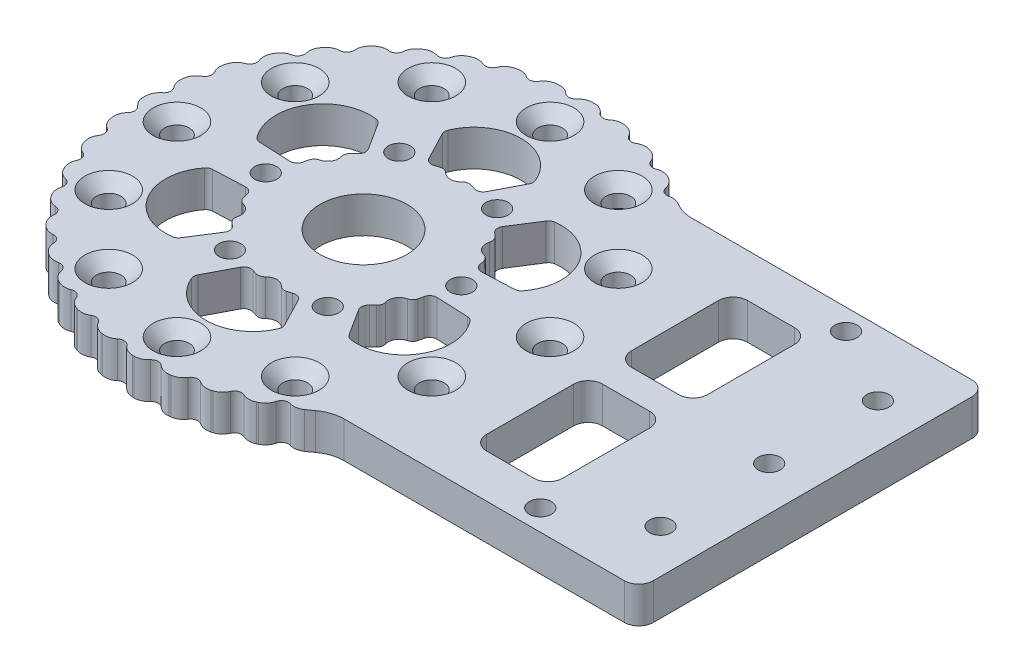
from build123d import *

# Parameters (mm, degrees)
EXTRUDE_1_DEPTH                = 5
SKETCH_2_R                     = 1.275
CUT_EXTRUDE_1_DEPTH            = 6
SKETCH_5_R                     = 10
CUT_EXTRUDE_3_DEPTH            = 6
SKETCH_6_R                     = 1.525
CUT_EXTRUDE_4_DEPTH            = 6
SKETCH_9_R                     = 12.5
CUT_EXTRUDE_7_DEPTH            = 6
HOLE_WIZARD_M3_1_D             = 3.6
HOLE_WIZARD_M3_1_CSINK_D       = 6.6
HOLE_WIZARD_M3_1_CSINK_ANGLE   = 90
HOLE_WIZARD_1_D                = 3
HOLE_WIZARD_1_CSINK_D          = 6
HOLE_WIZARD_1_CSINK_ANGLE      = 90
SKETCH_3_R                     = 2.025
CUT_EXTRUDE_8_DEPTH            = 10
SKETCH_14_R                    = 37
EXTRUDE_2_DEPTH                = 5
SKETCH_15_R                    = 42.5
EXTRUDE_3_DEPTH                = 5
SKETCH_16_R                    = 1.525
CUT_EXTRUDE_9_DEPTH            = 5
CUT_EXTRUDE_10_DEPTH           = 5
PATTERN_CIRCULAR_1_COUNT       = 6
SKETCH_19_R                    = 6
CUT_EXTRUDE_11_DEPTH           = 5
FILLET_1_R                     = 2
CUT_EXTRUDE_13_DEPTH           = 6
FILLET_2_R                     = 1
SKETCH_22_W                    = 180
SKETCH_22_H                    = 48
CUT_EXTRUDE_14_DEPTH           = 6.0000001
SKETCH_23_R                    = 1.525
CUT_EXTRUDE_15_DEPTH           = 6.0000001
SKETCH_27_R                    = 1.525
CUT_EXTRUDE_16_DEPTH           = 6.0000001
SKETCH_28_W                    = 10.5
SKETCH_28_H                    = 16
CUT_EXTRUDE_17_DEPTH           = 6.0000001
FILLET_3_R                     = 2
FILLET_5_R                     = 2
FILLET_6_R                     = 5
SKETCH_30_R                    = 1
CUT_EXTRUDE_18_DEPTH           = 6.0000001
PATTERN_CIRCULAR_2_COUNT       = 40
FILLET_7_R                     = 2
SKETCH_31_R                    = 1.525
CUT_EXTRUDE_19_DEPTH           = 6.0000001
SKETCH_32_R                    = 1.525
CUT_EXTRUDE_20_DEPTH           = 6.0000001
SKETCH_33_W                    = 62
SKETCH_33_H                    = 50.134149191
CUT_EXTRUDE_21_DEPTH           = 6.0000001
FILLET_8_R                     = 2
FILLET_9_R                     = 2
HOLE_WIZARD_M3_1_2_D           = 3.4
HOLE_WIZARD_M3_1_2_CSINK_D     = 6.6
HOLE_WIZARD_M3_1_2_CSINK_ANGLE = 90
HOLE_WIZARD_M3_2_D             = 3.4
HOLE_WIZARD_M3_2_CSINK_D       = 6.6
HOLE_WIZARD_M3_2_CSINK_ANGLE   = 90


with BuildPart() as part:
    # 草图1 → 凸台-拉伸1 (new body)
    with BuildSketch(Plane(origin=(0, 0, 0), x_dir=(1, 0, 0), z_dir=(0, 1, 0))):
        with BuildLine():
            Line((105, 24), (-76.839744319, 24))
            ThreePointArc((-76.839744319, 24), (-142, 0), (-76.839744319, -24))
            Line((-76.839744319, -24), (105, -24))
            ThreePointArc((105, -24), (129, 0), (105, 24))
        make_face()
    extrude(amount=EXTRUDE_1_DEPTH)

    # 草图2 → 切除-拉伸1 (cut, through all)
    with BuildSketch(Plane.XZ):
        with Locations((118.435028843, 13.435028843)):
            Circle(SKETCH_2_R)
        with Locations((118.435028843, -13.435028843)):
            Circle(SKETCH_2_R)
        with Locations((91.564971157, -13.435028843)):
            Circle(SKETCH_2_R)
        with Locations((91.564971157, 13.435028843)):
            Circle(SKETCH_2_R)
        with Locations((124, 0)):
            Circle(SKETCH_2_R)
        with Locations((105, -19)):
            Circle(SKETCH_2_R)
        with Locations((86, 0)):
            Circle(SKETCH_2_R)
        with Locations((105, 19)):
            Circle(SKETCH_2_R)
    extrude(amount=-CUT_EXTRUDE_1_DEPTH, mode=Mode.SUBTRACT)

    # 草图5 → 切除-拉伸3 (cut, through all)
    with BuildSketch(Plane(origin=(0, 5, 0), x_dir=(1, 0, 0), z_dir=(0, 1, 0))):
        with Locations((-105, 0)):
            Circle(SKETCH_5_R)
    extrude(amount=-CUT_EXTRUDE_3_DEPTH, mode=Mode.SUBTRACT)

    # 草图6 → 切除-拉伸4 (cut, through all)
    with BuildSketch(Plane(origin=(0, 5, 0), x_dir=(1, 0, 0), z_dir=(0, 1, 0))):
        with Locations((-135, 0)):
            Circle(SKETCH_6_R)
        with Locations((-120, 25.980762114)):
            Circle(SKETCH_6_R)
        with Locations((-90, 25.980762114)):
            Circle(SKETCH_6_R)
        with Locations((-75, 0)):
            Circle(SKETCH_6_R)
        with Locations((-90, -25.980762114)):
            Circle(SKETCH_6_R)
        with Locations((-120, -25.980762114)):
            Circle(SKETCH_6_R)
    extrude(amount=-CUT_EXTRUDE_4_DEPTH, mode=Mode.SUBTRACT)

    # 草图9 → 切除-拉伸7 (cut, through all)
    with BuildSketch(Plane.XZ):
        with Locations((105, 0)):
            Circle(SKETCH_9_R)
    extrude(amount=-CUT_EXTRUDE_7_DEPTH, mode=Mode.SUBTRACT)

    # Hole Wizard M3 _1 (through all)
    with Locations(Plane(origin=(0, 5, 0), x_dir=(1, 0, 0), z_dir=(0, 1, 0))):
        with Locations((105, 19)):
            CounterSinkHole(HOLE_WIZARD_M3_1_D / 2, HOLE_WIZARD_M3_1_CSINK_D / 2, counter_sink_angle=HOLE_WIZARD_M3_1_CSINK_ANGLE)

    # 孔1 (through all)
    with Locations(Plane(origin=(0, 5, 0), x_dir=(1, 0, 0), z_dir=(0, 1, 0))):
        with Locations((91.564971157, 13.435028843), (86, 0), (91.564971157, -13.435028843), (105, -19), (118.435028843, -13.435028843), (124, 0), (118.435028843, 13.435028843)):
            CounterSinkHole(HOLE_WIZARD_1_D / 2, HOLE_WIZARD_1_CSINK_D / 2, counter_sink_angle=HOLE_WIZARD_1_CSINK_ANGLE)

    # 草图3 → 切除-拉伸8 (cut)
    with BuildSketch(Plane(origin=(0, 5, 0), x_dir=(1, 0, 0), z_dir=(0, 1, 0))):
        with Locations((-105, 17.25)):
            Circle(SKETCH_3_R)
        with Locations((-90.061061785, 8.625)):
            Circle(SKETCH_3_R)
        with Locations((-90.061061785, -8.625)):
            Circle(SKETCH_3_R)
        with Locations((-105, -17.25)):
            Circle(SKETCH_3_R)
        with Locations((-119.938938215, -8.625)):
            Circle(SKETCH_3_R)
        with Locations((-119.938938215, 8.625)):
            Circle(SKETCH_3_R)
    extrude(amount=-CUT_EXTRUDE_8_DEPTH, mode=Mode.SUBTRACT)

    # 草图14 → 凸台-拉伸2 (add)
    with BuildSketch(Plane(origin=(0, 5, 0), x_dir=(1, 0, 0), z_dir=(0, 1, 0))):
        with Locations((-105, 0)):
            Circle(SKETCH_14_R)
    extrude(amount=-EXTRUDE_2_DEPTH)

    # 草图15 → 凸台-拉伸3 (add)
    with BuildSketch(Plane(origin=(0, 5, 0), x_dir=(1, 0, 0), z_dir=(0, 1, 0))):
        with Locations((-105, 0)):
            Circle(SKETCH_15_R)
    extrude(amount=-EXTRUDE_3_DEPTH)

    # 草图16 → 切除-拉伸9 (cut)
    with BuildSketch(Plane.XZ):
        with Locations((-105, 13.5)):
            Circle(SKETCH_16_R)
        with Locations((-98.25, 11.691342951)):
            Circle(SKETCH_16_R)
        with Locations((-93.308657049, 6.75)):
            Circle(SKETCH_16_R)
        with Locations((-91.5, 0)):
            Circle(SKETCH_16_R)
        with Locations((-93.308657049, -6.75)):
            Circle(SKETCH_16_R)
        with Locations((-98.25, -11.691342951)):
            Circle(SKETCH_16_R)
        with Locations((-105, -13.5)):
            Circle(SKETCH_16_R)
        with Locations((-111.75, -11.691342951)):
            Circle(SKETCH_16_R)
        with Locations((-116.691342951, -6.75)):
            Circle(SKETCH_16_R)
        with Locations((-118.5, 0)):
            Circle(SKETCH_16_R)
        with Locations((-116.691342951, 6.75)):
            Circle(SKETCH_16_R)
        with Locations((-111.75, 11.691342951)):
            Circle(SKETCH_16_R)
    extrude(amount=-CUT_EXTRUDE_9_DEPTH, mode=Mode.SUBTRACT)

    # 草图18 → 切除-拉伸10 (cut)
    with BuildSketch(Plane(origin=(0, 5, 0), x_dir=(1, 0, 0), z_dir=(0, 1, 0))):
        with BuildLine():
            Line((-98.815341562, 17.25), (-101.45814062, 12.173230244))
            ThreePointArc((-101.45814062, 12.173230244), (-105, 13), (-108.54185938, 12.173230244))
            Line((-108.54185938, 12.173230244), (-111.184658438, 17.25))
            ThreePointArc((-111.184658438, 17.25), (-105, 21.75), (-98.815341562, 17.25))
        make_face()
    cut_extrude_10 = extrude(amount=-CUT_EXTRUDE_10_DEPTH, mode=Mode.SUBTRACT)

    # 阵列(圆周)1: 切除-拉伸10 ×6 about axis
    pattern_circular_1_axis = Axis((-105, 0, 0), (0, 1, 0))
    for i in range(1, PATTERN_CIRCULAR_1_COUNT):
        add(cut_extrude_10.rotate(pattern_circular_1_axis, i * 360 / PATTERN_CIRCULAR_1_COUNT), mode=Mode.SUBTRACT)

    # 草图19 → 切除-拉伸11 (cut)
    with BuildSketch(Plane.XZ):
        with Locations((-105, 0)):
            Circle(SKETCH_19_R)
    extrude(amount=-CUT_EXTRUDE_11_DEPTH, mode=Mode.SUBTRACT)

    # 圆角1
    fillet_1_edges = [part.edges().sort_by_distance(p)[0] for p in [
        (-69.925080185, 2.5, 24),
        (-69.925080185, 2.5, -24),
    ]]
    fillet(fillet_1_edges, radius=FILLET_1_R)

    # 草图21 → 切除-拉伸13 (cut, through all)
    with BuildSketch(Plane.XZ):
        with BuildLine():
            ThreePointArc((-70.508717612, -24.831460674), (-69.797443095, -24.219960864), (-68.885598441, -24))
            Line((-68.885598441, -24), (-85.37858313, -24))
            ThreePointArc((-85.37858313, -24), (-136, 0), (-85.37858313, 24))
            Line((-85.37858313, 24), (-68.885598441, 24))
            ThreePointArc((-68.885598441, 24), (-69.797443095, 24.219960864), (-70.508717612, 24.831460674))
            ThreePointArc((-70.508717612, 24.831460674), (-147.5, 0), (-70.508717612, -24.831460674))
        make_face()
    extrude(amount=-CUT_EXTRUDE_13_DEPTH, mode=Mode.SUBTRACT)

    # 圆角2
    fillet_2_edges = [part.edges().sort_by_distance(p)[0] for p in [
        (-103.607655905, 2.5, -12.877904412),
        (-106.392344095, 2.5, -12.877904412),
        (-101.45814062, 2.5, -12.173230244),
        (-111.184658438, 2.5, -17.25),
        (-98.815341562, 2.5, -17.25),
        (-108.54185938, 2.5, -12.173230244),
        (-93.151235584, 2.5, -5.233146849),
        (-94.543579679, 2.5, -7.644757563),
        (-94.543579679, 2.5, 7.644757563),
        (-93.151235584, 2.5, 5.233146849),
        (-115.456420321, 2.5, -7.644757563),
        (-116.848764416, 2.5, -5.233146849),
        (-116.848764416, 2.5, 5.233146849),
        (-115.456420321, 2.5, 7.644757563),
        (-106.392344095, 2.5, 12.877904412),
        (-103.607655905, 2.5, 12.877904412),
        (-92.686743673, 2.5, -3.019274922),
        (-93.153391004, 2.5, -13.981071321),
        (-86.968732566, 2.5, -3.268928679),
        (-96.228603053, 2.5, -9.153955322),
        (-96.228603053, 2.5, 9.153955322),
        (-86.968732566, 2.5, 3.268928679),
        (-93.153391004, 2.5, 13.981071321),
        (-92.686743673, 2.5, 3.019274922),
        (-108.54185938, 2.5, 12.173230244),
        (-98.815341562, 2.5, 17.25),
        (-111.184658438, 2.5, 17.25),
        (-101.45814062, 2.5, 12.173230244),
        (-117.313256327, 2.5, 3.019274922),
        (-116.846608996, 2.5, 13.981071321),
        (-123.031267434, 2.5, 3.268928679),
        (-113.771396947, 2.5, 9.153955322),
        (-113.771396947, 2.5, -9.153955322),
        (-123.031267434, 2.5, -3.268928679),
        (-116.846608996, 2.5, -13.981071321),
        (-117.313256327, 2.5, -3.019274922),
    ]]
    fillet(fillet_2_edges, radius=FILLET_2_R)

    # 草图22 → 切除-拉伸14 (cut, through all)
    with BuildSketch(Plane.XZ):
        with Locations((55, 0)):
            Rectangle(SKETCH_22_W, SKETCH_22_H)
    extrude(amount=-CUT_EXTRUDE_14_DEPTH, mode=Mode.SUBTRACT)

    # 草图23 → 切除-拉伸15 (cut, through all)
    with BuildSketch(Plane.XZ):
        with Locations((-117.875, 22.300154147)):
            Circle(SKETCH_23_R)
        with Locations((-105, 25.75)):
            Circle(SKETCH_23_R)
        with Locations((-92.125, 22.300154147)):
            Circle(SKETCH_23_R)
        with Locations((-82.699845853, 12.875)):
            Circle(SKETCH_23_R)
        with Locations((-79.25, 0)):
            Circle(SKETCH_23_R)
        with Locations((-82.699845853, -12.875)):
            Circle(SKETCH_23_R)
        with Locations((-92.125, -22.300154147)):
            Circle(SKETCH_23_R)
        with Locations((-105, -25.75)):
            Circle(SKETCH_23_R)
        with Locations((-117.875, -22.300154147)):
            Circle(SKETCH_23_R)
        with Locations((-127.300154147, -12.875)):
            Circle(SKETCH_23_R)
        with Locations((-130.75, 0)):
            Circle(SKETCH_23_R)
        with Locations((-127.300154147, 12.875)):
            Circle(SKETCH_23_R)
    extrude(amount=-CUT_EXTRUDE_15_DEPTH, mode=Mode.SUBTRACT)

    # 草图27 → 切除-拉伸16 (cut, through all)
    with BuildSketch(Plane.XZ):
        with Locations((-38, 0)):
            Circle(SKETCH_27_R)
        with Locations((-38, 20)):
            Circle(SKETCH_27_R)
        with Locations((-38, -20)):
            Circle(SKETCH_27_R)
    extrude(amount=-CUT_EXTRUDE_16_DEPTH, mode=Mode.SUBTRACT)

    # 草图28 → 切除-拉伸17 (cut, through all)
    with BuildSketch(Plane.XZ):
        with Locations((-66.75, 10)):
            Rectangle(SKETCH_28_W, SKETCH_28_H)
        with Locations((-66.75, -10)):
            Rectangle(SKETCH_28_W, SKETCH_28_H)
    extrude(amount=-CUT_EXTRUDE_17_DEPTH, mode=Mode.SUBTRACT)

    # 圆角3
    fillet_3_edges = [part.edges().sort_by_distance(p)[0] for p in [
        (-72, 2.5, 2),
        (-72, 2.5, 18),
        (-61.5, 2.5, 18),
        (-61.5, 2.5, 2),
    ]]
    fillet(fillet_3_edges, radius=FILLET_3_R)

    # 圆角5
    fillet_5_edges = [part.edges().sort_by_distance(p)[0] for p in [
        (-35, 2.5, 24),
        (-35, 2.5, -24),
    ]]
    fillet(fillet_5_edges, radius=FILLET_5_R)

    # 圆角6
    fillet_6_edges = [part.edges().sort_by_distance(p)[0] for p in [
        (-85.37858313, 2.5, 24),
        (-85.37858313, 2.5, -24),
    ]]
    fillet(fillet_6_edges, radius=FILLET_6_R)

    # 草图30 → 切除-拉伸18 (cut, through all)
    with BuildSketch(Plane.XZ):
        with Locations((-113.023390398, 29.943700615)):
            Circle(SKETCH_30_R)
    cut_extrude_18 = extrude(amount=-CUT_EXTRUDE_18_DEPTH, mode=Mode.SUBTRACT)

    # 阵列(圆周)2: 切除-拉伸18 ×40 about axis, 12 skipped
    pattern_circular_2_axis = Axis((-105, 0, 0), (0, -1, 0))
    add([cut_extrude_18.rotate(pattern_circular_2_axis, i * 360 / PATTERN_CIRCULAR_2_COUNT) for i in range(1, PATTERN_CIRCULAR_2_COUNT) if i not in (23, 24, 25, 26, 27, 28, 29, 30, 31, 32, 33, 34)], mode=Mode.SUBTRACT)

    # 圆角7
    fillet_7_edges = [part.edges().sort_by_distance(p)[0] for p in [
        (-86.631872243, 2.5, -24.972222222),
        (-112.05341572, 2.5, 30.186906544),
        (-113.985016075, 2.5, 29.669335789),
        (-107.244303892, 2.5, 30.918652947),
        (-109.233088945, 2.5, 30.709623215),
        (-102.379929853, 2.5, 30.889079501),
        (-104.376929117, 2.5, 30.993737798),
        (-97.580070637, 2.5, 30.098914403),
        (-99.536111361, 2.5, 30.514683694),
        (-92.962914707, 2.5, 28.56761414),
        (-94.829832677, 2.5, 29.284256805),
        (-88.642151766, 2.5, 26.332884406),
        (-90.373977266, 2.5, 27.332754325),
        (-105.623070883, 2.5, -30.993737798),
        (-107.620070147, 2.5, -30.889079501),
        (-100.766911055, 2.5, -30.709623215),
        (-102.755696108, 2.5, -30.918652947),
        (-96.014983925, 2.5, -29.669335789),
        (-97.94658428, 2.5, -30.186906544),
        (-91.484297711, 2.5, -27.898490849),
        (-93.311150956, 2.5, -28.711858317),
        (-87.286412943, 2.5, -25.440692474),
        (-88.963535888, 2.5, -26.529828849),
        (-110.463888639, 2.5, -30.514683694),
        (-112.419929363, 2.5, -30.098914403),
        (-115.170167323, 2.5, -29.284256805),
        (-117.037085293, 2.5, -28.56761414),
        (-119.626022734, 2.5, -27.332754325),
        (-121.357848234, 2.5, -26.332884406),
        (-123.721736924, 2.5, -24.708228721),
        (-125.275826663, 2.5, -23.449751665),
        (-127.356459818, 2.5, -21.475304524),
        (-128.694546948, 2.5, -19.989208212),
        (-130.440692474, 2.5, -17.713587057),
        (-131.529828849, 2.5, -16.036464112),
        (-132.898490849, 2.5, -13.515702289),
        (-133.711858317, 2.5, -11.688849044),
        (-134.669335789, 2.5, -8.985016075),
        (-135.186906544, 2.5, -7.05341572),
        (-135.709623215, 2.5, -4.233088945),
        (-135.918652947, 2.5, -2.244303892),
        (-135.993737798, 2.5, 0.623070883),
        (-135.889079501, 2.5, 2.620070147),
        (-135.514683694, 2.5, 5.463888639),
        (-135.098914403, 2.5, 7.419929363),
        (-134.284256805, 2.5, 10.170167323),
        (-133.56761414, 2.5, 12.037085293),
        (-132.332754325, 2.5, 14.626022734),
        (-131.332884406, 2.5, 16.357848234),
        (-129.708228721, 2.5, 18.721736924),
        (-128.449751665, 2.5, 20.275826663),
        (-126.475304524, 2.5, 22.356459818),
        (-124.989208212, 2.5, 23.694546948),
        (-122.713587057, 2.5, 25.440692474),
        (-121.036464112, 2.5, 26.529828849),
        (-118.515702289, 2.5, 27.898490849),
        (-116.688849044, 2.5, 28.711858317),
    ]]
    fillet(fillet_7_edges, radius=FILLET_7_R)

    # 草图31 → 切除-拉伸19 (cut, through all)
    with BuildSketch(Plane.XZ):
        with Locations((-59.5, 21.1)):
            Circle(SKETCH_31_R)
        with Locations((-59.5, -21.1)):
            Circle(SKETCH_31_R)
    extrude(amount=-CUT_EXTRUDE_19_DEPTH, mode=Mode.SUBTRACT)

    # 草图32 → 切除-拉伸20 (cut, through all)
    with BuildSketch(Plane.XZ):
        with Locations((-49, 0)):
            Circle(SKETCH_32_R)
        with Locations((-49, 15)):
            Circle(SKETCH_32_R)
        with Locations((-49, -15)):
            Circle(SKETCH_32_R)
    extrude(amount=-CUT_EXTRUDE_20_DEPTH, mode=Mode.SUBTRACT)

    # 草图33 → 切除-拉伸21 (cut, through all)
    with BuildSketch(Plane.XZ):
        with Locations((-12, -1.067074596)):
            Rectangle(SKETCH_33_W, SKETCH_33_H)
    extrude(amount=-CUT_EXTRUDE_21_DEPTH, mode=Mode.SUBTRACT)

    # 圆角8
    fillet_8_edges = [part.edges().sort_by_distance(p)[0] for p in [
        (-72, 2.5, -2),
        (-61.5, 2.5, -2),
        (-61.5, 2.5, -18),
        (-72, 2.5, -18),
    ]]
    fillet(fillet_8_edges, radius=FILLET_8_R)

    # 圆角9
    fillet_9_edges = [part.edges().sort_by_distance(p)[0] for p in [
        (-43, 2.5, -24),
        (-43, 2.5, 24),
    ]]
    fillet(fillet_9_edges, radius=FILLET_9_R)

    # Hole Wizard M3 _1 2 (through all)
    with Locations(Plane(origin=(0, 0, 0), x_dir=(-1, 0, 0), z_dir=(0, -1, 0))):
        with Locations((92.125, 22.300154147)):
            CounterSinkHole(HOLE_WIZARD_M3_1_2_D / 2, HOLE_WIZARD_M3_1_2_CSINK_D / 2, counter_sink_angle=HOLE_WIZARD_M3_1_2_CSINK_ANGLE)

    # M3 开槽半沉头木螺钉的锥形沉头孔2 (through all)
    with Locations(Plane(origin=(0, 5, 0), x_dir=(1, 0, 0), z_dir=(0, 1, 0))):
        with Locations((-105, 25.75), (-92.125, 22.300154147), (-117.875, 22.300154147), (-127.300154147, 12.875), (-130.75, 0), (-127.300154147, -12.875), (-117.875, -22.300154147), (-105, -25.75), (-92.125, -22.300154147), (-82.699845853, -12.875), (-79.25, 0), (-82.699845853, 12.875)):
            CounterSinkHole(HOLE_WIZARD_M3_2_D / 2, HOLE_WIZARD_M3_2_CSINK_D / 2, counter_sink_angle=HOLE_WIZARD_M3_2_CSINK_ANGLE)


solid = part.part
